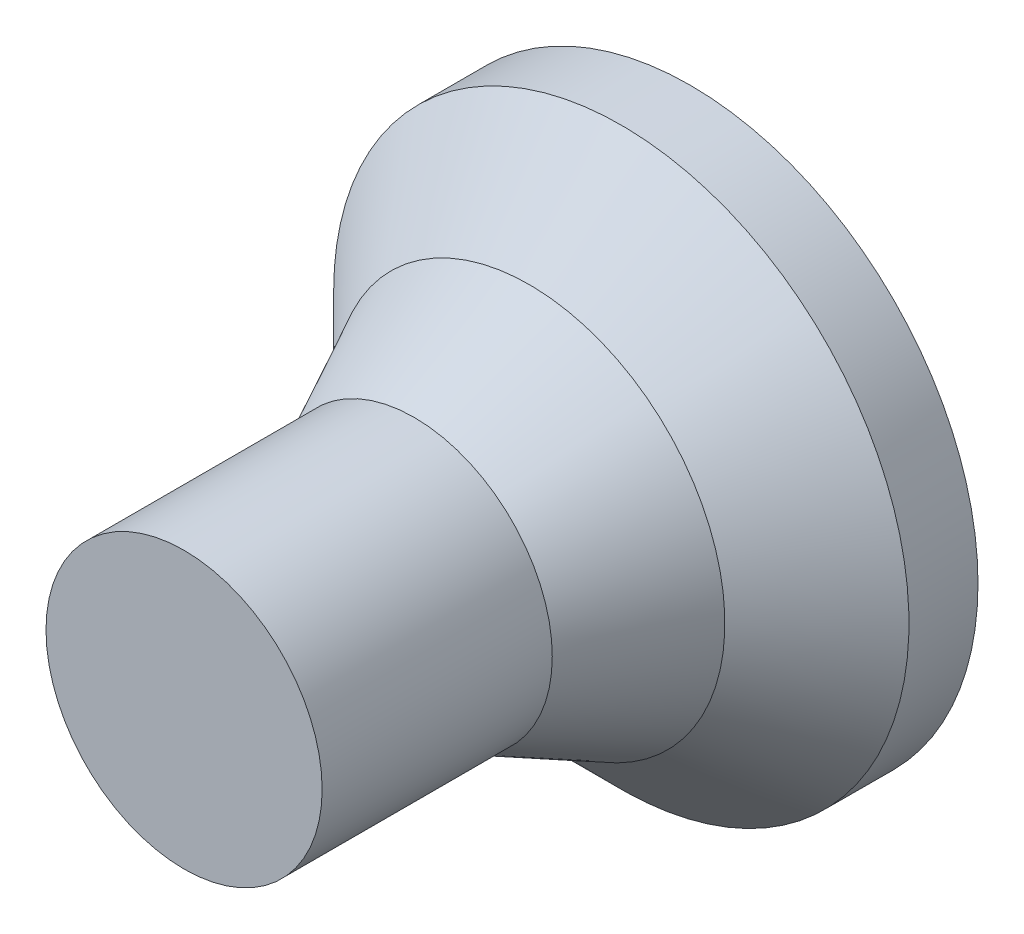
from build123d import *

# Parameters (mm, degrees)
SKETCH_1_R      = 125
EXTRUDE_1_DEPTH = 30
SKETCH_4_R      = 60
EXTRUDE_2_DEPTH = 100
SKETCH_3_R      = 85


with BuildPart() as part:
    # ｽｹｯﾁ1 → ﾎﾞｽ - 押し出し1 (new body)
    with BuildSketch(Plane.XY):
        Circle(SKETCH_1_R)
    extrude(amount=EXTRUDE_1_DEPTH)

    # ｽｹｯﾁ3 → section 0 of loft_1
    with BuildSketch(Plane(origin=(0, 0, 70), x_dir=(-1, 0, 0), z_dir=(0, 0, -1)), mode=Mode.PRIVATE) as loft_1_s0:
        Circle(SKETCH_3_R)
    # loft up to a face of the part (loft_1)
    loft([loft_1_s0.sketch, Face(Wire([part.edges().sort_by_distance((-85.568388241, 91.121078428, 30))[0]]))])



with BuildPart() as body_2:
    # ｽｹｯﾁ4 → ﾎﾞｽ - 押し出し2 (new body)
    with BuildSketch(Plane(origin=(0, 0, 120), x_dir=(-1, 0, 0), z_dir=(0, 0, -1))):
        Circle(SKETCH_4_R)
    extrude(amount=-EXTRUDE_2_DEPTH)


with BuildPart() as part_1:
    add(part.part)

    add(body_2.part)  # loft_2 joins it to this body
    # loft from a face of the part (loft_2)
    loft([part_1.faces().sort_by_distance((0, 0, 70))[0], part_1.faces().sort_by_distance((0, 0, 120))[0]])


solid = part_1.part
